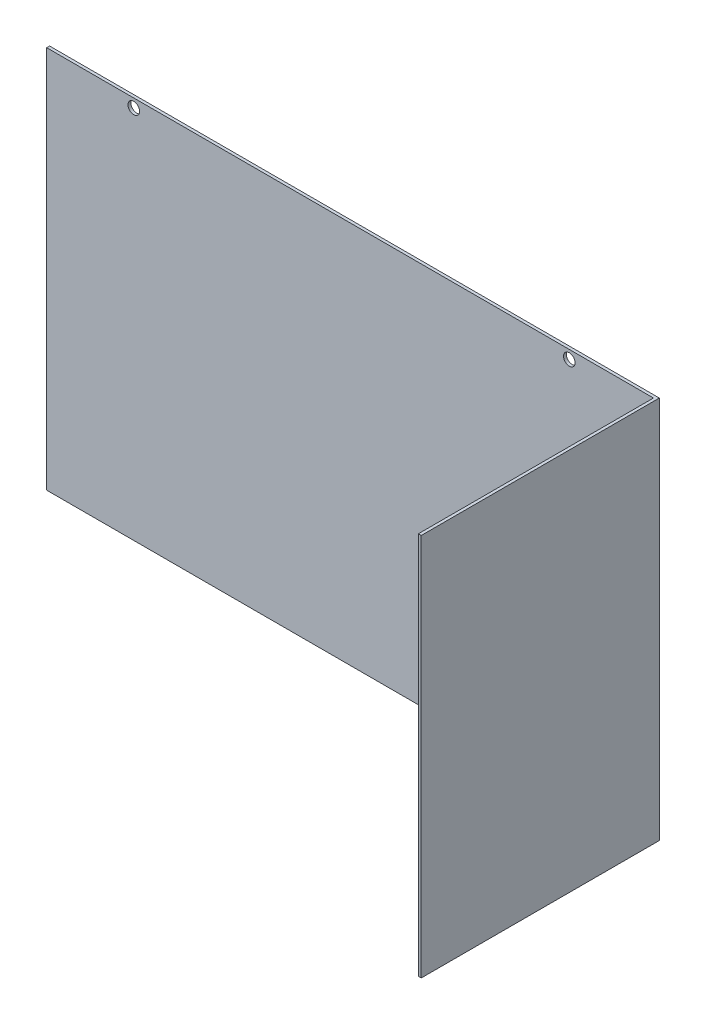
from build123d import *

# Parameters (mm, degrees)
SKETCH_1_W          = 210
SKETCH_1_H          = 132
EXTRUDE_1_DEPTH     = 1
SKETCH_3_W          = 1
SKETCH_3_H          = 132
EXTRUDE_2_DEPTH     = 81
SKETCH_2_R          = 2
CUT_EXTRUDE_1_DEPTH = 1


with BuildPart() as part:
    # 草图1 → 凸台-拉伸1 (new body)
    with BuildSketch(Plane.XY):
        Rectangle(SKETCH_1_W, SKETCH_1_H)
    extrude(amount=EXTRUDE_1_DEPTH)

    # 草图3 → 凸台-拉伸2 (add)
    with BuildSketch(Plane.XY.offset(1)):
        with Locations((104.5, 0)):
            Rectangle(SKETCH_3_W, SKETCH_3_H)
    extrude(amount=EXTRUDE_2_DEPTH)

    # 草图2 → 切除-拉伸1 (cut)
    with BuildSketch(Plane.XY.offset(1)):
        with Locations((-75, 63)):
            Circle(SKETCH_2_R)
        with Locations((75, 63)):
            Circle(SKETCH_2_R)
    extrude(amount=-CUT_EXTRUDE_1_DEPTH, mode=Mode.SUBTRACT)


solid = part.part
